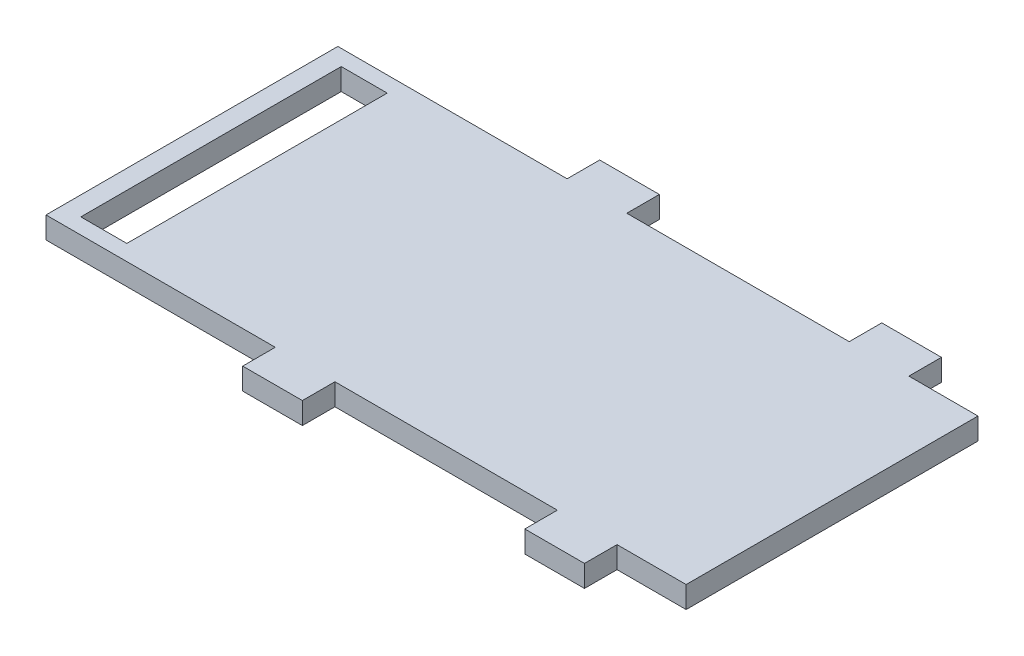
from build123d import *

# Parameters (mm, degrees)
SKETCH1_W              = 29.5
SKETCH1_H              = 13.45
BOSS_EXTRUDE1_DEPTH    = 1
SKETCH2_W              = 2.75
SKETCH2_H              = 1.5
BOSS_EXTRUDE2_DEPTH    = 1
SKETCH3_W              = 2.12
SKETCH3_H              = 12
ADAPTER_PCB_HOLE_DEPTH = 1


with BuildPart() as part:
    # Sketch1 → Boss-Extrude1 (new body)
    with BuildSketch(Plane(origin=(0, 0, 0), x_dir=(1, 0, 0), z_dir=(0, 1, 0))):
        with Locations((-36.048423651, -12.055454233)):
            Rectangle(SKETCH1_W, SKETCH1_H)
    extrude(amount=BOSS_EXTRUDE1_DEPTH)

    # Sketch2 → Boss-Extrude2 (add)
    with BuildSketch(Plane(origin=(0, 0, 0), x_dir=(1, 0, 0), z_dir=(0, 1, 0))):
        with Locations((-38.858423651, -4.580454233)):
            Rectangle(SKETCH2_W, SKETCH2_H)
        with Locations((-38.858423651, -19.530454233)):
            Rectangle(SKETCH2_W, SKETCH2_H)
        with Locations((-25.858423651, -4.580454233)):
            Rectangle(SKETCH2_W, SKETCH2_H)
        with Locations((-25.858423651, -19.530454233)):
            Rectangle(SKETCH2_W, SKETCH2_H)
    extrude(amount=BOSS_EXTRUDE2_DEPTH)

    # Sketch3 → adapter_PCB_hole (cut)
    with BuildSketch(Plane(origin=(0, 0, 0), x_dir=(-1, 0, 0), z_dir=(0, -1, 0))):
        with Locations((48.858423651, -12.055454233)):
            Rectangle(SKETCH3_W, SKETCH3_H)
    extrude(amount=-ADAPTER_PCB_HOLE_DEPTH, mode=Mode.SUBTRACT)


solid = part.part
